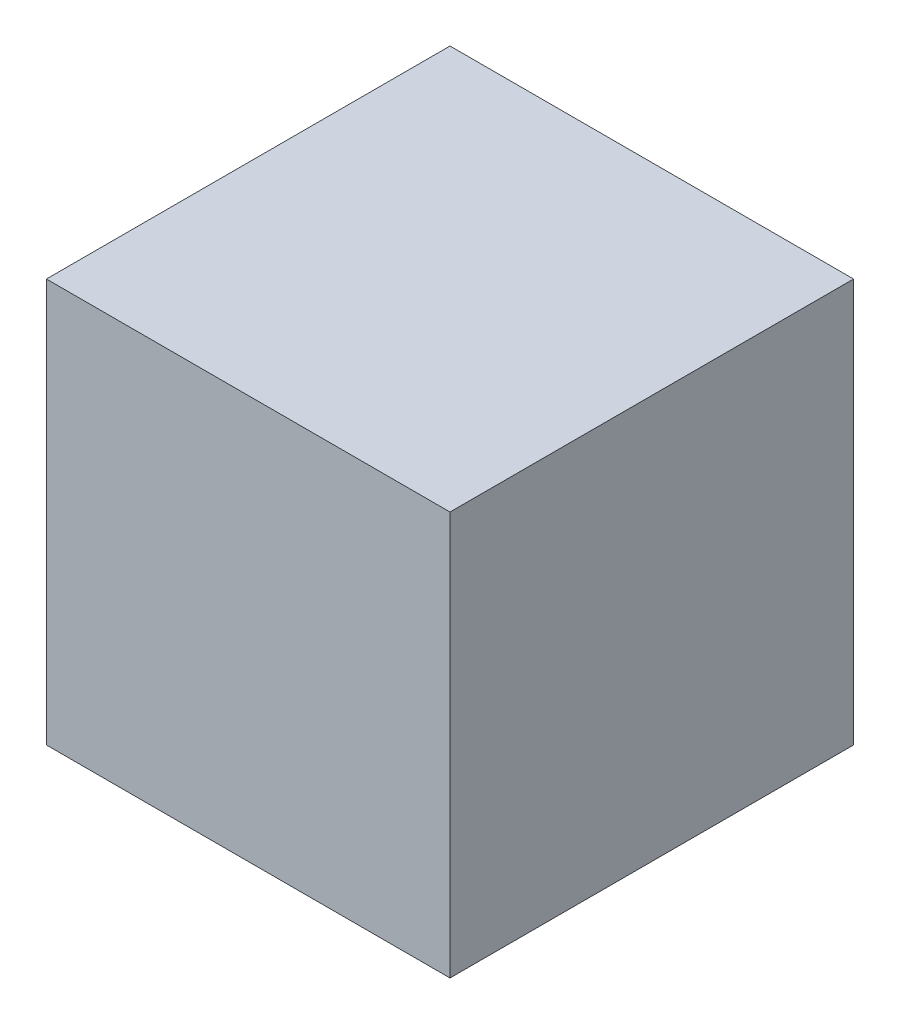
from build123d import *

# Parameters (mm, degrees)
SKETCH_1_W      = 700
SKETCH_1_H      = 700
EXTRUDE_1_DEPTH = 700


with BuildPart() as part:
    # ｽｹｯﾁ1 → ﾎﾞｽ - 押し出し1 (new body)
    with BuildSketch(Plane.XY):
        with Locations((350, 350)):
            Rectangle(SKETCH_1_W, SKETCH_1_H)
    extrude(amount=EXTRUDE_1_DEPTH)


solid = part.part
